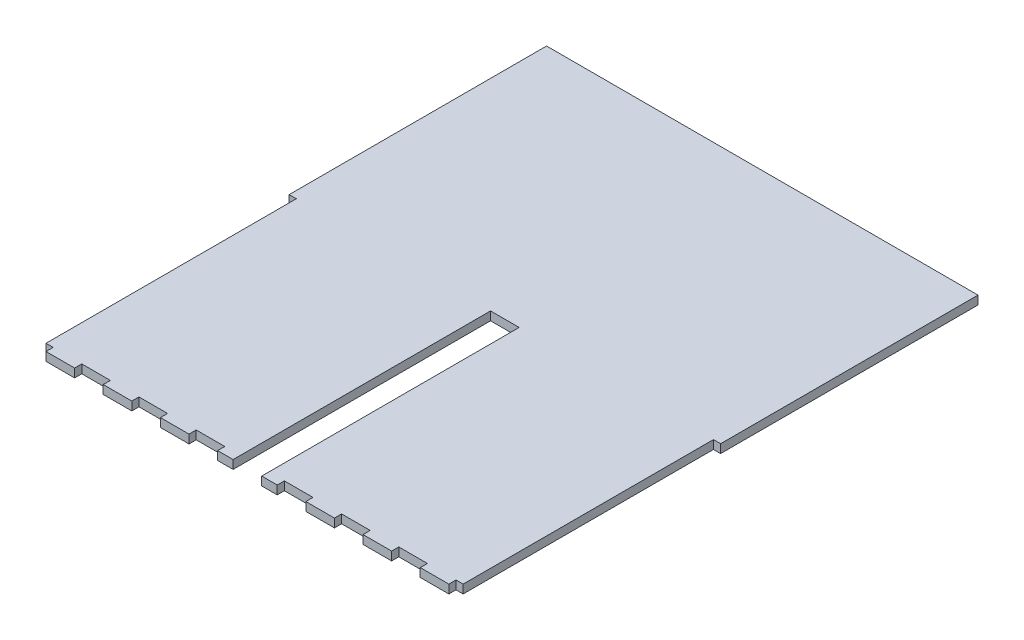
from build123d import *

# Parameters (mm, degrees)
BOSS_EXTRUDE1_DEPTH = 3.6


with BuildPart() as part:
    # Sketch1 → Boss-Extrude1 (new body)
    with BuildSketch(Plane(origin=(0, 0, 0), x_dir=(1, 0, 0), z_dir=(0, 1, 0))):
        Polygon((-90.5, 0), (-87.5, 0), (-87.5, -105), (-84.5, -105), (-84.5, -108), (-72.5, -108), (-72.5, -105), (-60.5, -105), (-60.5, -108), (-48.5, -108), (-48.5, -105), (-36.5, -105), (-36.5, -108), (-24.5, -108), (-24.5, -105), (-12.5, -105), (-12.5, -108), (-6, -108), (-6, 0), (6, 0), (6, -108), (12.5, -108), (12.5, -105), (24.5, -105), (24.5, -108), (36.5, -108), (36.5, -105), (48.5, -105), (48.5, -108), (60.5, -108), (60.5, -105), (72.5, -105), (72.5, -108), (84.5, -108), (84.5, -105), (87.5, -105), (87.5, 0), (90.5, 0), (90.5, 108), (-90.5, 108), align=None)
    extrude(amount=BOSS_EXTRUDE1_DEPTH)


solid = part.part
